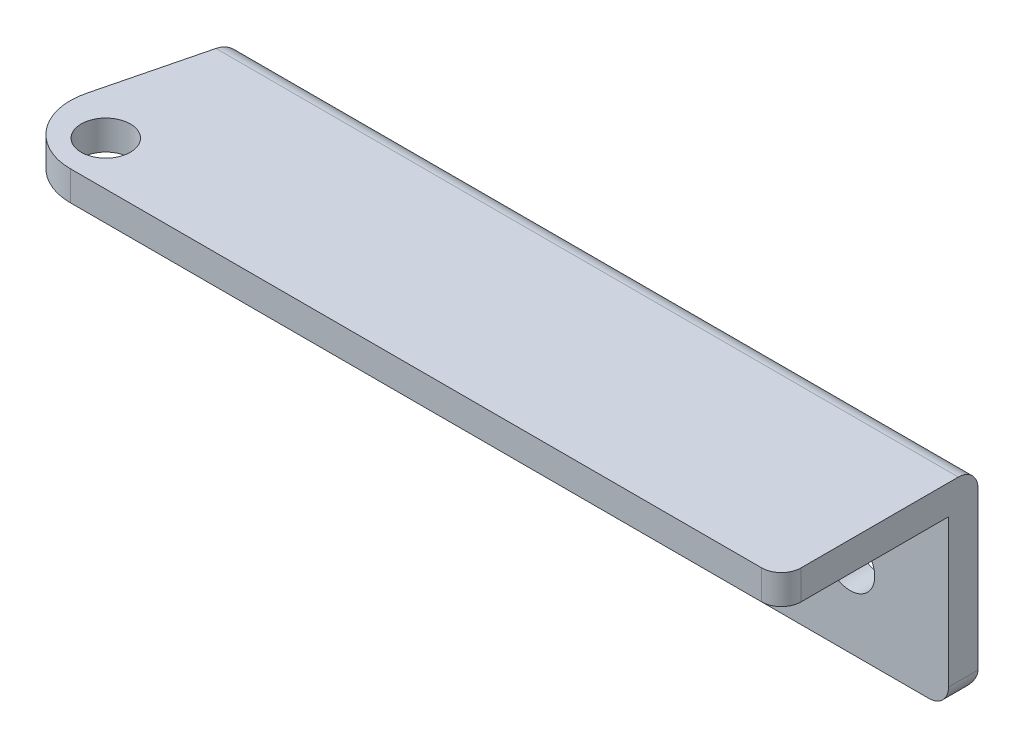
from build123d import *

# Parameters (mm, degrees)
SKETCH1_W           = 75
SKETCH1_H           = 3
BOSS_EXTRUDE1_DEPTH = 20
SKETCH2_W           = 75
SKETCH2_H           = 17
BOSS_EXTRUDE2_DEPTH = 3
FILLET1_R           = 6
FILLET2_R           = 2
SKETCH3_R           = 2.5
CUT_EXTRUDE1_DEPTH  = 21
SKETCH4_R           = 2.5
CUT_EXTRUDE2_DEPTH  = 4


with BuildPart() as part:
    # Sketch1 → Boss-Extrude1 (new body)
    with BuildSketch(Plane(origin=(0, 0, 0), x_dir=(1, 0, 0), z_dir=(0, 1, 0))):
        with Locations((37.5, 1.5)):
            Rectangle(SKETCH1_W, SKETCH1_H)
    extrude(amount=BOSS_EXTRUDE1_DEPTH)

    # Sketch2 → Boss-Extrude2 (add)
    with BuildSketch(Plane(origin=(0, 20, 0), x_dir=(1, 0, 0), z_dir=(0, 1, 0))):
        Polygon((0, 0), (0, 3), (-5, -17), (0, -17), align=None)
        with Locations((37.5, -8.5)):
            Rectangle(SKETCH2_W, SKETCH2_H)
    extrude(amount=-BOSS_EXTRUDE2_DEPTH)

    # Fillet1
    fillet1_edges = [part.edges().sort_by_distance(p)[0] for p in [
        (-5, 18.5, 17),
    ]]
    fillet(fillet1_edges, radius=FILLET1_R)

    # Fillet2
    fillet2_edges = [part.edges().sort_by_distance(p)[0] for p in [
        (37.5, 20, -3),
        (75, 18.5, 17),
        (37.5, 0, -3),
        (75, 0, -1.5),
        (0, 0, -1.5),
    ]]
    fillet(fillet2_edges, radius=FILLET2_R)

    # Sketch3 → Cut-Extrude1 (cut, through all)
    with BuildSketch(Plane(origin=(0, 20, 0), x_dir=(1, 0, 0), z_dir=(0, 1, 0))):
        with Locations((1.794270235, -12.5)):
            Circle(SKETCH3_R)
    extrude(amount=-CUT_EXTRUDE1_DEPTH, mode=Mode.SUBTRACT)

    # Sketch4 → Cut-Extrude2 (cut, through all)
    with BuildSketch(Plane.XY):
        with Locations((65, 8)):
            Circle(SKETCH4_R)
        with Locations((15, 8)):
            Circle(SKETCH4_R)
    extrude(amount=-CUT_EXTRUDE2_DEPTH, mode=Mode.SUBTRACT)


solid = part.part
